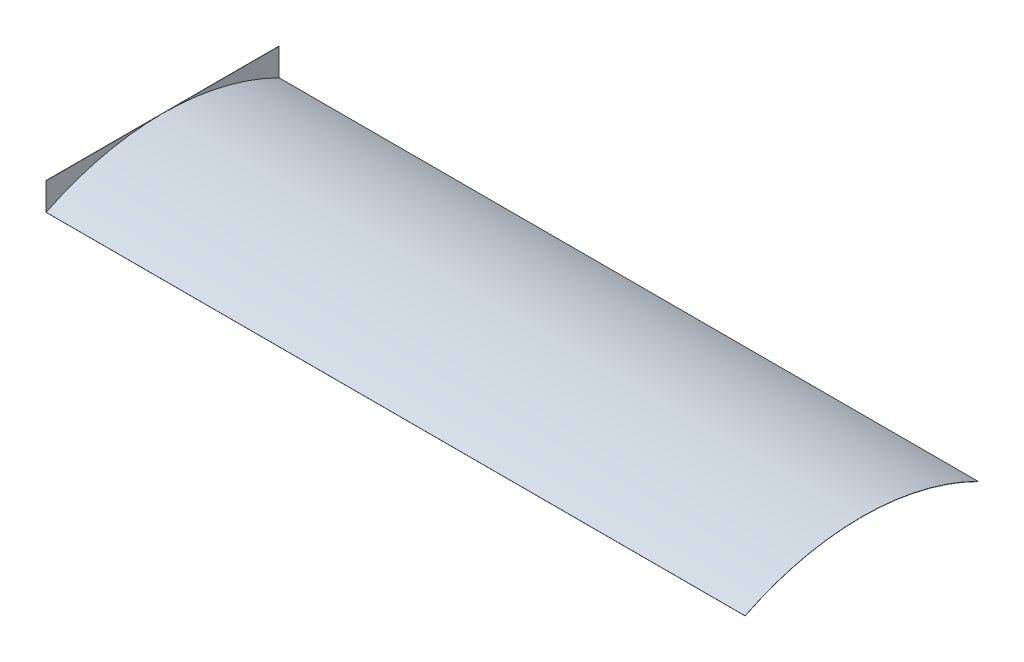
from build123d import *

# Parameters (mm, degrees)
SKETCH1_W           = 2.54
SKETCH1_H           = 2590.8
EXTRUDE_THIN1_DEPTH = 304.8
EXTRUDE_THIN2_DEPTH = 7772.4


with BuildPart() as part:
    # Sketch1 → Extrude-Thin1 (new body)
    with BuildSketch(Plane(origin=(0, 0, 0), x_dir=(1, 0, 0), z_dir=(0, 1, 0))):
        with Locations((-1.27, -1295.4)):
            Rectangle(SKETCH1_W, SKETCH1_H)
    extrude(amount=EXTRUDE_THIN1_DEPTH)

    # Sketch3 → Extrude-Thin2 (add)
    with BuildSketch(Plane(origin=(0, 0, 0), x_dir=(0, 0, -1), z_dir=(1, 0, 0))):
        with BuildLine():
            ThreePointArc((-2590.8, 0), (-1295.4, 304.8), (0, 0))
            Line((0, 0), (-1.132590164, -2.273508197))
            ThreePointArc((-1.132590164, -2.273508197), (-1295.4, 302.26), (-2589.667409836, -2.273508197))
            Line((-2589.667409836, -2.273508197), (-2590.8, 0))
        make_face()
    extrude(amount=EXTRUDE_THIN2_DEPTH)


solid = part.part
